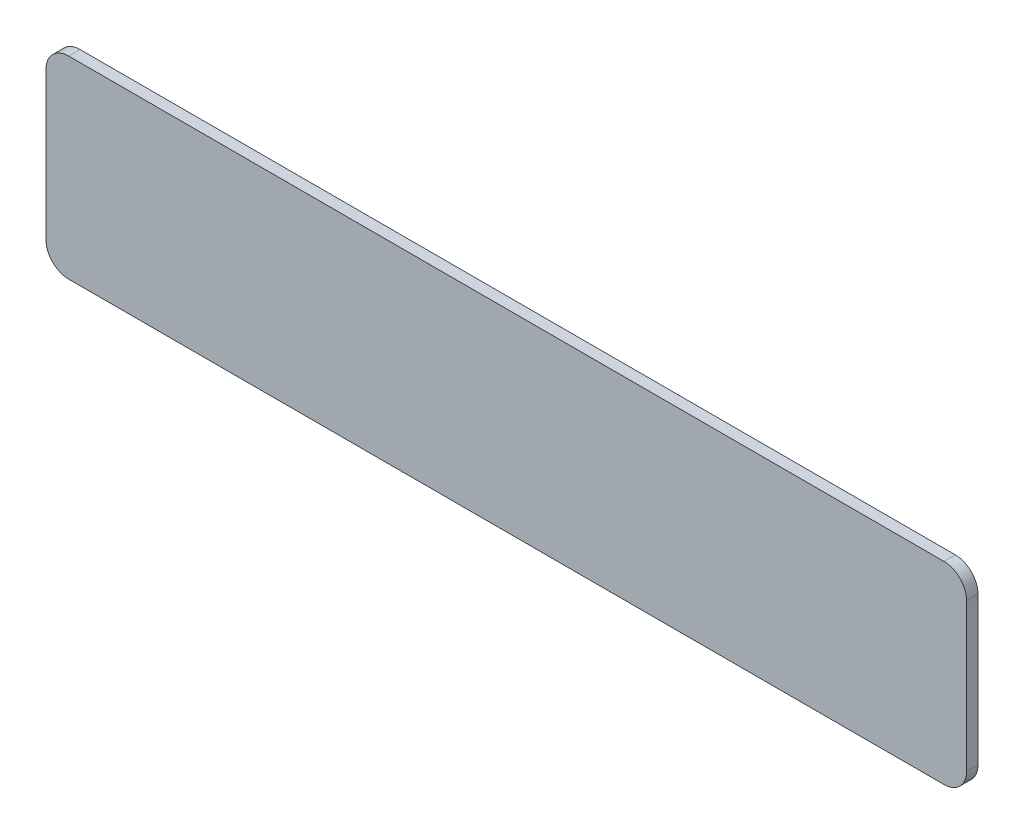
from build123d import *

# Parameters (mm, degrees)
BOSS_EXTRUDE1_DEPTH = 1


with BuildPart() as part:
    # Sketch1 → Boss-Extrude1 (new body)
    with BuildSketch(Plane.XY):
        with BuildLine():
            Line((-38.5, 8.5), (38.5, 8.5))
            ThreePointArc((38.5, 8.5), (39.914213562, 7.914213562), (40.5, 6.5))
            Line((40.5, 6.5), (40.5, -6.5))
            ThreePointArc((40.5, -6.5), (39.914213562, -7.914213562), (38.5, -8.5))
            Line((38.5, -8.5), (-38.5, -8.5))
            ThreePointArc((-38.5, -8.5), (-39.914213562, -7.914213562), (-40.5, -6.5))
            Line((-40.5, -6.5), (-40.5, 6.5))
            ThreePointArc((-40.5, 6.5), (-39.914213562, 7.914213562), (-38.5, 8.5))
        make_face()
    extrude(amount=BOSS_EXTRUDE1_DEPTH)


solid = part.part
